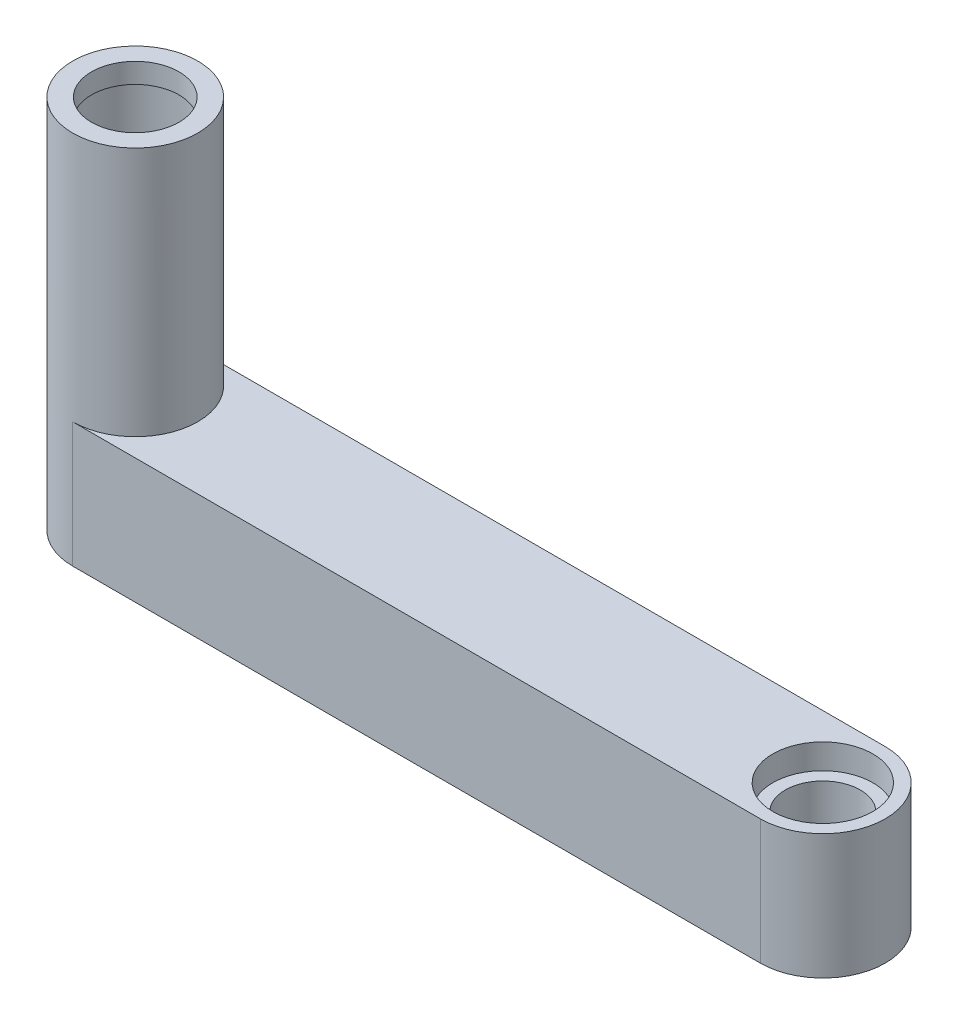
from build123d import *

# Parameters (mm, degrees)
RECTWITHARC_W              = 275
RECTWITHARC_H              = 50
ARMBASE_DEPTH              = 50
ARMCOLLAR_START            = 50
SKETCH5_R                  = 25
ARMCOLLAR_DEPTH            = 100
CUT_EXTRUDE1_REACH         = 152
SHAFTKEY_R                 = 17.5
HOLLOWMIDDLE_DEPTH         = 15
HOLLOWMIDDLE_DEPTH_BACK    = 26
J2SHAFTHOLE_R              = 15
JOINT2SHAFTHOLE_DEPTH      = 151
JOINT2SHAFTHOLE_DEPTH_BACK = 10
J2SHAFTCOUNTERSINK_START   = 50
SKETCH4_R                  = 20
J2SHAFTCOUNTERSINK_DEPTH   = 10
SKETCH6_R                  = 21
INNERDIAMETER_DEPTH        = 142
CUT_EXTRUDE11_DEPTH        = 10
CUT_EXTRUDE12_START        = 10
SKETCH9_W                  = 50
SKETCH9_H                  = 20
CUT_EXTRUDE12_DEPTH        = 5
CUT_EXTRUDE13_START        = 10
SKETCH11_R                 = 2.5
CUT_EXTRUDE13_DEPTH        = 5


with BuildPart() as part:
    # RectwithArc → ArmBase (new body)
    with BuildSketch(Plane(origin=(0, 0, 0), x_dir=(1, 0, 0), z_dir=(0, 1, 0))):
        with BuildLine():
            ThreePointArc((0, -25), (-25, 0), (0, 25))
            Line((0, 25), (0, -25))
        make_face()
        with Locations((137.5, 0)):
            Rectangle(RECTWITHARC_W, RECTWITHARC_H)
        with BuildLine():
            Line((275, 25), (275, -25))
            ThreePointArc((275, -25), (300, 0), (275, 25))
        make_face()
    extrude(amount=ARMBASE_DEPTH)

    # Sketch5 → ArmCollar (add)
    with BuildSketch(Plane(origin=(0, 0, 0), x_dir=(1, 0, 0), z_dir=(0, 1, 0)).offset(ARMCOLLAR_START)):
        Circle(SKETCH5_R)
    extrude(amount=ARMCOLLAR_DEPTH)

    # ShaftKey → Cut-Extrude1 (cut, up to next)
    with BuildSketch(Plane(origin=(0, 0, 0), x_dir=(1, 0, 0), z_dir=(0, 1, 0)), mode=Mode.PRIVATE) as cut_extrude1_sk1:
        Circle(SHAFTKEY_R)
    cut_extrude1_tool1 = extrude(cut_extrude1_sk1.sketch, amount=CUT_EXTRUDE1_REACH, mode=Mode.PRIVATE) & part.part
    add(cut_extrude1_tool1.solids().sort_by_distance((0, 0, 0))[0], mode=Mode.SUBTRACT)

    # Sketch1 → HollowMIddle (cut, two sides)
    with BuildSketch(Plane.XY) as hollowmiddle_sk:
        Polygon((20, 40), (250, 40), (250, 10), (70, 10), (70, 15), (20, 15), align=None)
    extrude(amount=HOLLOWMIDDLE_DEPTH, mode=Mode.SUBTRACT)
    extrude(hollowmiddle_sk.sketch, amount=-HOLLOWMIDDLE_DEPTH_BACK, mode=Mode.SUBTRACT)

    # J2ShaftHole → Joint2ShaftHole (cut, two sides)
    with BuildSketch(Plane(origin=(0, 0, 0), x_dir=(1, 0, 0), z_dir=(0, 1, 0))) as joint2shafthole_sk:
        with Locations((275, 0)):
            Circle(J2SHAFTHOLE_R)
    extrude(amount=JOINT2SHAFTHOLE_DEPTH, mode=Mode.SUBTRACT)
    extrude(joint2shafthole_sk.sketch, amount=-JOINT2SHAFTHOLE_DEPTH_BACK, mode=Mode.SUBTRACT)

    # Sketch4 → J2ShaftCounterSink (cut)
    with BuildSketch(Plane(origin=(0, 0, 0), x_dir=(1, 0, 0), z_dir=(0, 1, 0)).offset(J2SHAFTCOUNTERSINK_START)):
        with Locations((275, 0)):
            Circle(SKETCH4_R)
    extrude(amount=-J2SHAFTCOUNTERSINK_DEPTH, mode=Mode.SUBTRACT)

    # Sketch6 → InnerDiameter (cut)
    with BuildSketch(Plane(origin=(0, 0, 0), x_dir=(1, 0, 0), z_dir=(0, 1, 0))):
        Circle(SKETCH6_R)
    extrude(amount=INNERDIAMETER_DEPTH, mode=Mode.SUBTRACT)

    # Sketch10 → Cut-Extrude11 (cut)
    with BuildSketch(Plane(origin=(0, 0, 0), x_dir=(1, 0, 0), z_dir=(0, 1, 0))):
        with BuildLine():
            Line((0, 22.5), (50, 22.5))
            Line((50, 22.5), (50, -22.5))
            Line((50, -22.5), (0, -22.5))
            ThreePointArc((0, -22.5), (-22.5, 0), (0, 22.5))
        make_face()
    extrude(amount=CUT_EXTRUDE11_DEPTH, mode=Mode.SUBTRACT)

    # Sketch9 → Cut-Extrude12 (cut)
    with BuildSketch(Plane(origin=(0, 0, 0), x_dir=(1, 0, 0), z_dir=(0, 1, 0)).offset(CUT_EXTRUDE12_START)):
        with Locations((25, 0)):
            Rectangle(SKETCH9_W, SKETCH9_H)
    extrude(amount=CUT_EXTRUDE12_DEPTH, mode=Mode.SUBTRACT)

    # Sketch11 → Cut-Extrude13 (cut)
    with BuildSketch(Plane(origin=(0, 0, 0), x_dir=(1, 0, 0), z_dir=(0, 1, 0)).offset(CUT_EXTRUDE13_START)):
        with Locations((30, 16.25)):
            Circle(SKETCH11_R)
        with Locations((30, -16.25)):
            Circle(SKETCH11_R)
    extrude(amount=CUT_EXTRUDE13_DEPTH, mode=Mode.SUBTRACT)


solid = part.part
